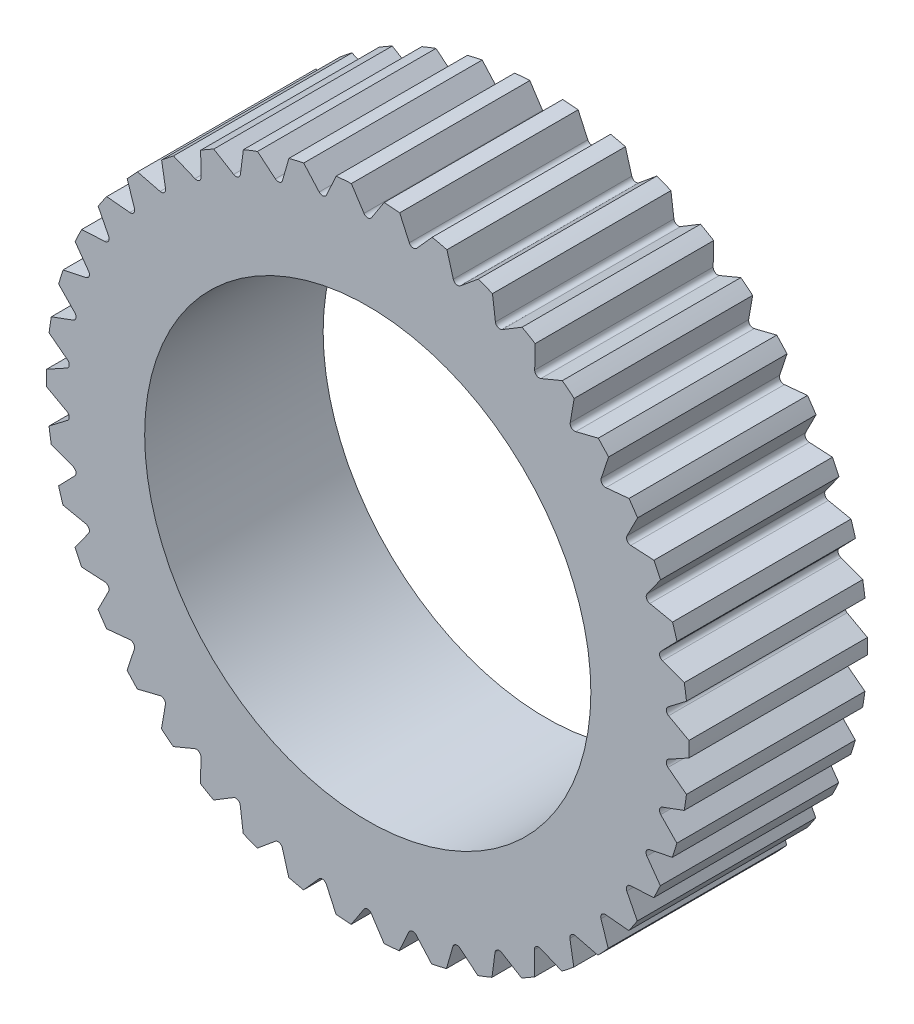
from build123d import *

# Parameters (mm, degrees)
SKETCH1_R           = 3.6
SKETCH1_R_2         = 2.5
BOSS_EXTRUDE1_DEPTH = 2
CUT_EXTRUDE5_DEPTH  = 2
CIRPATTERN1_COUNT   = 42
CIRPATTERN1_ANGLE   = 351.37


with BuildPart() as part:
    # Sketch1 → Boss-Extrude1 (new body)
    with BuildSketch(Plane.XY):
        Circle(SKETCH1_R)
        Circle(SKETCH1_R_2, mode=Mode.SUBTRACT)
    extrude(amount=BOSS_EXTRUDE1_DEPTH)

    # Sketch2 → Cut-Extrude5 (cut)
    with BuildSketch(Plane.XY.offset(2)):
        with BuildLine():
            Line((0.127706505, 3.508912523), (0.1331563, 3.517268902))
            Line((0.1331563, 3.517268902), (0.243655843, 3.686702076))
            Line((0.243655843, 3.686702076), (-0.206279812, 3.629391979))
            Line((-0.206279812, 3.629391979), (-0.1331563, 3.517268902))
            Line((-0.1331563, 3.517268902), (-0.127706505, 3.508912523))
            Line((-0.127706505, 3.508912523), (-0.04188057, 3.377312335))
            ThreePointArc((-0.04188057, 3.377312335), (0, 3.354625662), (0.04188057, 3.377312335))
            Line((0.04188057, 3.377312335), (0.127706505, 3.508912523))
        make_face()
    cut_extrude5 = extrude(amount=-CUT_EXTRUDE5_DEPTH, mode=Mode.SUBTRACT)

    # CirPattern1: Cut-Extrude5 ×42 about axis
    cirpattern1_axis = Axis((0, 0, 0), (0, 0, 1))
    for i in range(1, CIRPATTERN1_COUNT):
        add(cut_extrude5.rotate(cirpattern1_axis, i * CIRPATTERN1_ANGLE / (CIRPATTERN1_COUNT - 1)), mode=Mode.SUBTRACT)


solid = part.part
